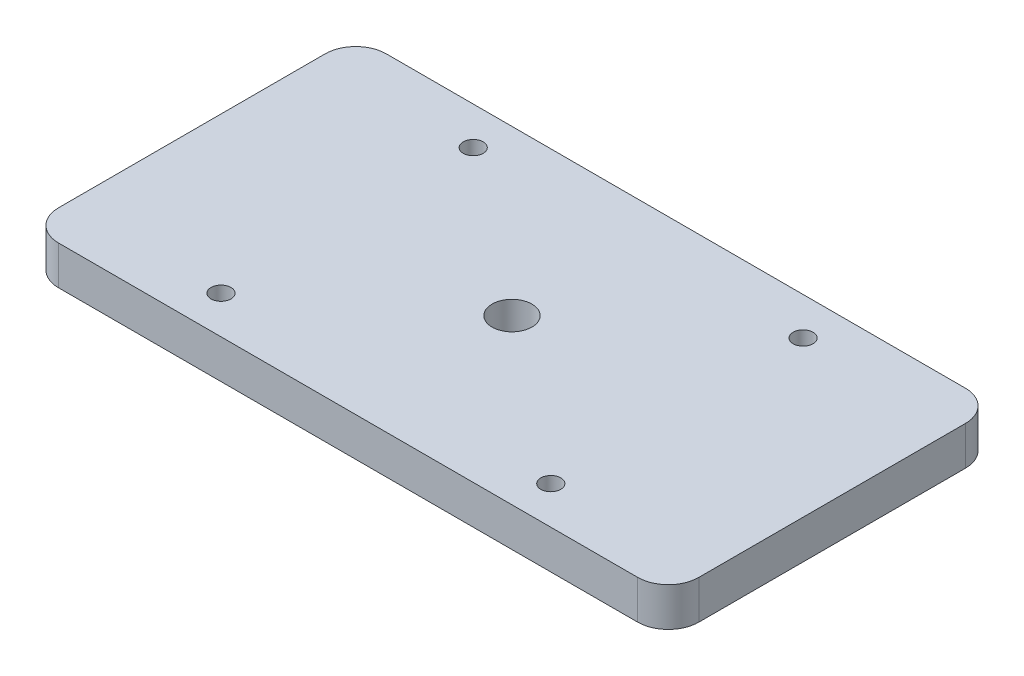
from build123d import *

# Parameters (mm, degrees)
SKETCH1_W                    = 104.775
SKETCH1_H                    = 53.63
BOSS_EXTRUDE1_DEPTH          = 6.35
F_0_257_DIAMETER_HOLE1_D     = 6.5278
FILLET1_R                    = 5
F_30_0_1285_DIAMETER_HOLE1_D = 3.2639


with BuildPart() as part:
    # Sketch1 → Boss-Extrude1 (new body)
    with BuildSketch(Plane(origin=(0, 0, 0), x_dir=(1, 0, 0), z_dir=(0, 1, 0))):
        with Locations((52.3875, 26.815)):
            Rectangle(SKETCH1_W, SKETCH1_H)
    extrude(amount=BOSS_EXTRUDE1_DEPTH)

    # F (0.257) Diameter Hole1 (through all)
    with Locations(Plane(origin=(0, 0, 0), x_dir=(-1, 0, 0), z_dir=(0, -1, 0))):
        with Locations((-52.385, 26.815)):
            Hole(F_0_257_DIAMETER_HOLE1_D / 2)

    # Fillet1
    fillet1_edges = [part.edges().sort_by_distance(p)[0] for p in [
        (0, 3.175, -53.63),
        (104.775, 3.175, -53.63),
        (104.775, 3.175, 0),
        (0, 3.175, 0),
    ]]
    fillet(fillet1_edges, radius=FILLET1_R)

    # #30 (0.1285) Diameter Hole1 (through all)
    with Locations(Plane(origin=(0, 0, 0), x_dir=(-1, 0, 0), z_dir=(0, -1, 0))):
        with Locations((-25.4, 6.1775), (-25.4, 47.4525), (-79.375, 47.4525), (-79.375, 6.1775)):
            Hole(F_30_0_1285_DIAMETER_HOLE1_D / 2)


solid = part.part
